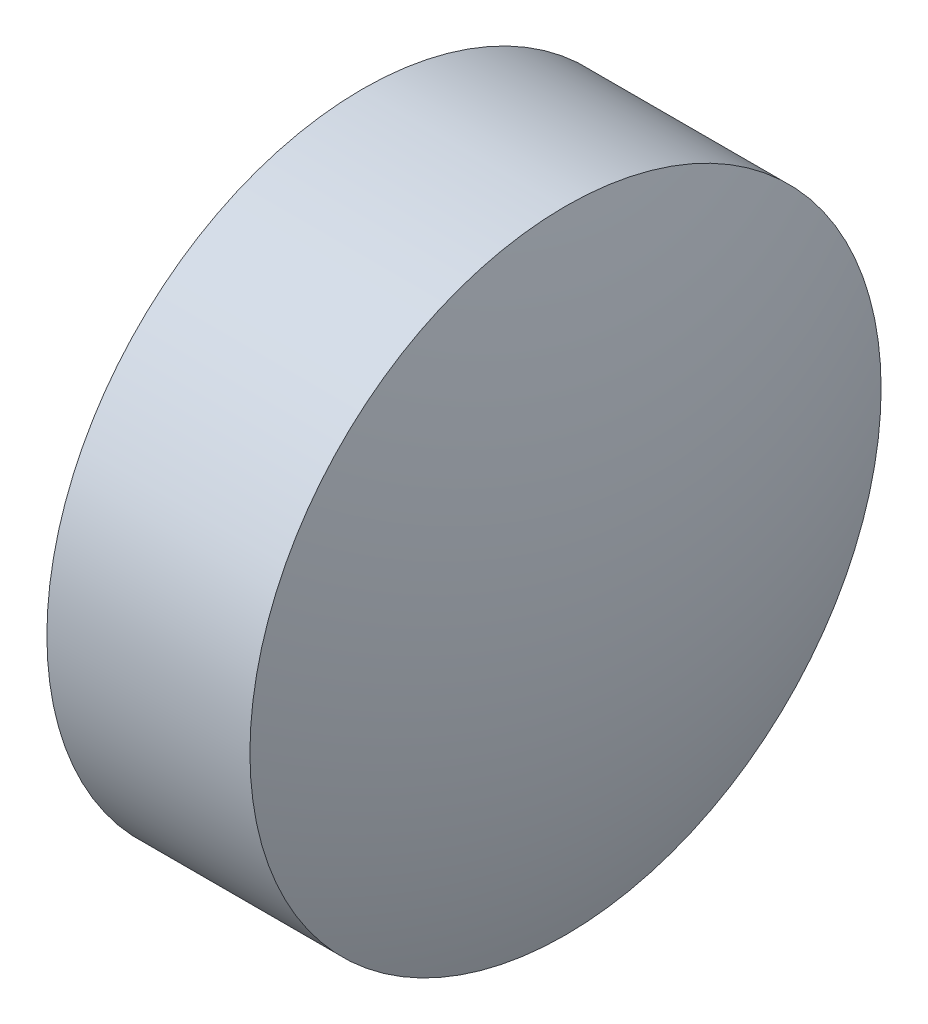
from build123d import *

# Parameters (mm, degrees)
SKETCH_1_ONE_SIDE_W = 1.929994286
SKETCH_1_ONE_SIDE_H = 3


with BuildPart() as part:
    # 草图1 one side → 旋转1 (revolve)
    with BuildSketch(Plane.XY, mode=Mode.PRIVATE) as revolve_1_sk:
        with Locations((20.42319538, 12.984121187)):
            Rectangle(SKETCH_1_ONE_SIDE_W, SKETCH_1_ONE_SIDE_H)
        with BuildLine():
            Line((18.923203951, 11.484121187), (19.458198237, 11.484121187))
            Line((19.458198237, 11.484121187), (19.458198237, 14.484121187))
            ThreePointArc((19.458198237, 14.484121187), (19.057999314, 13.007786085), (18.923203951, 11.484121187))
        make_face()
        with BuildLine():
            Line((21.388192523, 11.484121187), (21.923186808, 11.484121187))
            ThreePointArc((21.923186808, 11.484121187), (21.788391446, 13.007786085), (21.388192523, 14.484121187))
            Line((21.388192523, 14.484121187), (21.388192523, 11.484121187))
        make_face()
    revolve(revolve_1_sk.sketch.rotate(Axis((17.394947656, 11.484121187, 0), (1, 0, 0)), 90), axis=Axis((17.394947656, 11.484121187, 0), (1, 0, 0)))  # turned: the seam where the file's is


solid = part.part
